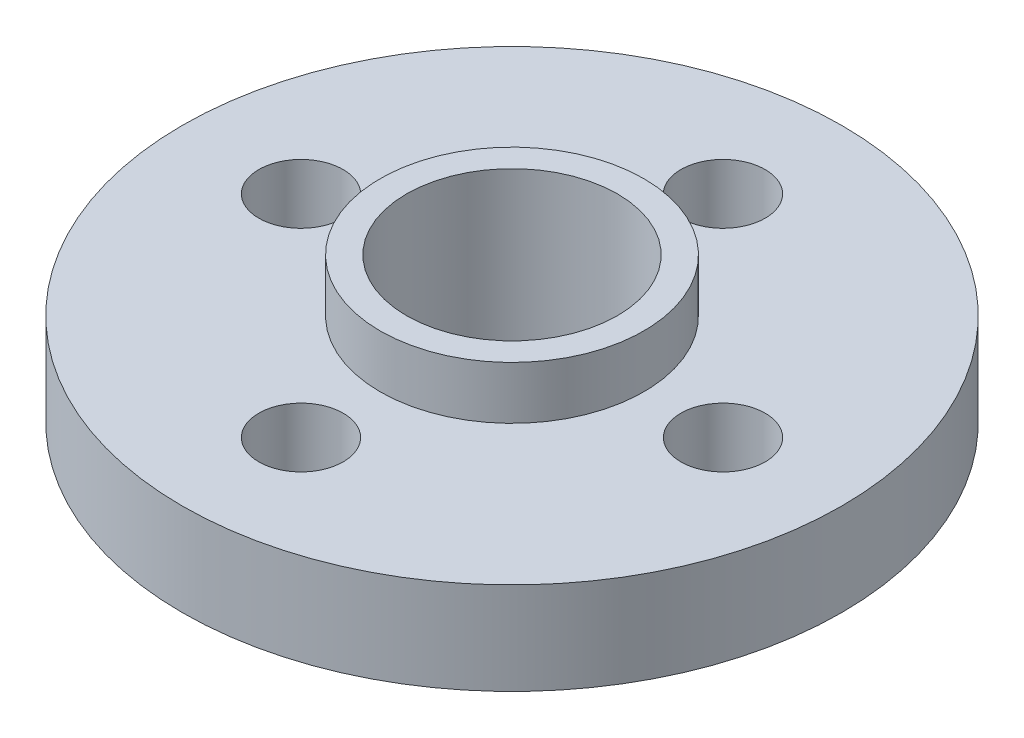
from build123d import *

# Parameters (mm, degrees)
SKETCH2_R           = 12.5
SKETCH2_R_2         = 4
BOSS_EXTRUDE1_DEPTH = 3.5
SKETCH3_R           = 5
SKETCH3_R_2         = 4
BOSS_EXTRUDE2_DEPTH = 2
SKETCH4_R           = 5
SKETCH4_R_2         = 4
BOSS_EXTRUDE3_DEPTH = 5
SKETCH5_R           = 1.6
CUT_EXTRUDE1_DEPTH  = 9.5


with BuildPart() as part:
    # Sketch2 → Boss-Extrude1 (new body)
    with BuildSketch(Plane(origin=(0, 0, 0), x_dir=(1, 0, 0), z_dir=(0, 1, 0))):
        Circle(SKETCH2_R)
        Circle(SKETCH2_R_2, mode=Mode.SUBTRACT)
    extrude(amount=BOSS_EXTRUDE1_DEPTH)

    # Sketch3 → Boss-Extrude2 (add)
    with BuildSketch(Plane(origin=(0, 3.5, 0), x_dir=(1, 0, 0), z_dir=(0, 1, 0))):
        Circle(SKETCH3_R)
        Circle(SKETCH3_R_2, mode=Mode.SUBTRACT)
    extrude(amount=BOSS_EXTRUDE2_DEPTH)

    # Sketch4 → Boss-Extrude3 (add)
    with BuildSketch(Plane.XZ):
        Circle(SKETCH4_R)
        Circle(SKETCH4_R_2, mode=Mode.SUBTRACT)
    extrude(amount=BOSS_EXTRUDE3_DEPTH)

    # Sketch5 → Cut-Extrude1 (cut, through all)
    with BuildSketch(Plane(origin=(0, 3.5, 0), x_dir=(1, 0, 0), z_dir=(0, 1, 0))):
        with Locations((0, 8)):
            Circle(SKETCH5_R)
        with Locations((8, 0)):
            Circle(SKETCH5_R)
        with Locations((0, -8)):
            Circle(SKETCH5_R)
        with Locations((-8, 0)):
            Circle(SKETCH5_R)
    extrude(amount=-CUT_EXTRUDE1_DEPTH, mode=Mode.SUBTRACT)


solid = part.part
